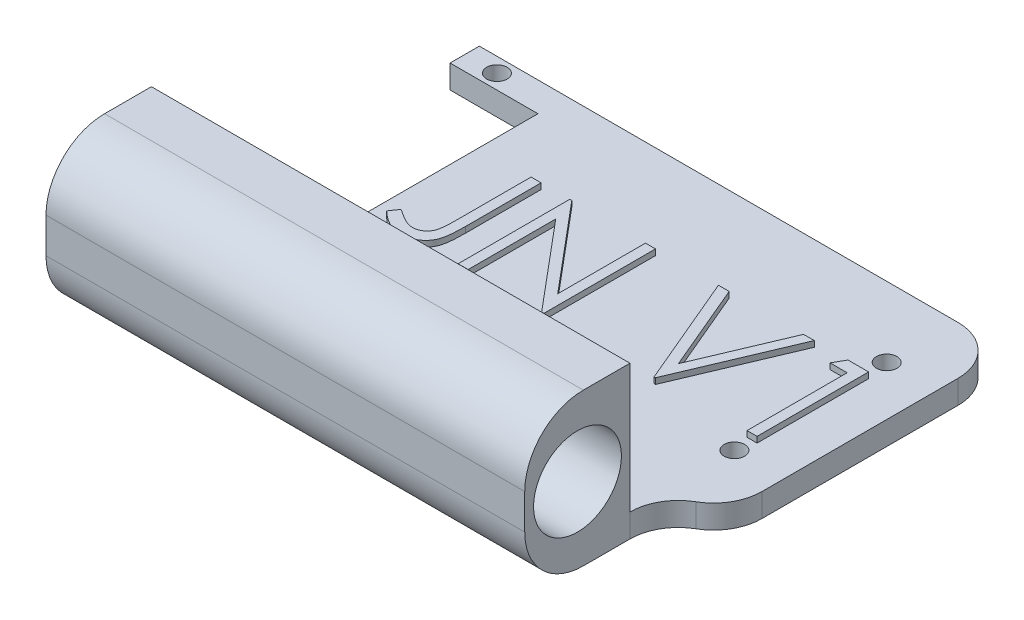
from build123d import *

# Parameters (mm, degrees)
SKETCH1_R           = 1.75
BOSS_EXTRUDE1_DEPTH = 4
FILLET1_R           = 8.25
SKETCH2_W           = 81.75
SKETCH2_H           = 4
BOSS_EXTRUDE2_DEPTH = 24
FILLET3_R           = 8.25
BOSS_EXTRUDE4_DEPTH = 1
BOSS_EXTRUDE6_DEPTH = 22
SKETCH7_R           = 7.5
CUT_EXTRUDE2_DEPTH  = 115
FILLET6_R           = 10


with BuildPart() as part:
    # Sketch1 → Boss-Extrude1 (new body)
    with BuildSketch(Plane(origin=(0, 0, 0), x_dir=(1, 0, 0), z_dir=(0, 1, 0))):
        Polygon((0, 45), (15, 45), (15, 5), (0, 5), (0, 0), (90, 0), (90, 50), (0, 50), align=None)
        with Locations(Location((5.5, 2.5, 0), (0, 0, 270))):
            Circle(SKETCH1_R, mode=Mode.SUBTRACT)
        with Locations(Location((5.5, 47.5, 0), (0, 0, 270))):
            Circle(SKETCH1_R, mode=Mode.SUBTRACT)
        with Locations(Location((81.55, 12, 0), (0, 0, 270))):
            Circle(SKETCH1_R, mode=Mode.SUBTRACT)
        with Locations(Location((81.55, 38, 0), (0, 0, 270))):
            Circle(SKETCH1_R, mode=Mode.SUBTRACT)
    extrude(amount=BOSS_EXTRUDE1_DEPTH)

    # Fillet1
    fillet1_edges = [part.edges().sort_by_distance(p)[0] for p in [
        (90, 2, -50),
        (90, 2, 0),
    ]]
    fillet(fillet1_edges, radius=FILLET1_R)

    # Sketch2 → Boss-Extrude2 (add)
    with BuildSketch(Plane.XY):
        with Locations((40.875, 2)):
            Rectangle(SKETCH2_W, SKETCH2_H)
    extrude(amount=BOSS_EXTRUDE2_DEPTH)

    # Fillet3
    fillet3_edges = [part.edges().sort_by_distance(p)[0] for p in [
        (81.75, 2, 0),
    ]]
    fillet(fillet3_edges, radius=FILLET3_R)

    # Sketch5 → Boss-Extrude4 (add)
    with BuildSketch(Plane(origin=(0, 4, 0), x_dir=(1, 0, 0), z_dir=(0, 1, 0))):
        Polygon((78.896003606, 34.05), (82.418269231, 34.05), (82.418269231, 15), (80.708653846, 15), (80.708653846, 32.096153846), (77.777884615, 32.096153846), align=None)
        Polygon((56.774038462, 34.05), (58.605769231, 34.05), (64.955769231, 19.037439904), (71.305769231, 34.05), (73.1375, 34.05), (65.077884615, 15), (64.833653846, 15), align=None)
        Polygon((31.374038462, 15), (31.374038462, 34.05), (31.732752404, 34.05), (44.318269231, 19.056520433), (44.318269231, 34.05), (46.027884615, 34.05), (46.027884615, 15), (45.638641827, 15), (33.083653846, 29.959134615), (33.083653846, 15), align=None)
        with BuildLine():
            Line((24.779807692, 34.05), (26.489423077, 34.05))
            Line((26.489423077, 34.05), (26.489423077, 21.185907452))
            add(Edge.make_bspline(
                [(26.489423077, 21.185907452), (26.487714463, 20.94802645), (26.484433715, 20.4912659), (26.466393852, 19.833366552), (26.433010208, 19.232634675), (26.384378211, 18.68770427), (26.319498087, 18.200282505), (26.245251919, 17.766603171), (26.155375115, 17.390285757), (26.020030491, 16.967727607), (25.798103714, 16.504302041), (25.464091692, 16.003803293), (25.049167471, 15.566015729), (24.568557562, 15.185817326), (24.018061417, 14.882882968), (23.409015395, 14.66541264), (22.745168684, 14.532765549), (22.284707257, 14.518756151), (22.047475962, 14.511538462)],
                knots=[0, 0, 0, 0, 1.237770943, 2.376671248, 3.424123796, 4.367912054, 5.222547132, 5.982086412, 6.656319012, 7.234008312, 8.288027371, 9.317870876, 10.352700517, 11.413286737, 12.494591526, 13.606319346, 14.766767577, 16, 16, 16, 16], degree=3))
            add(Edge.make_bspline(
                [(22.047475962, 14.511538462), (21.862645469, 14.517420063), (21.490754275, 14.529254234), (20.937266275, 14.625710986), (20.385349806, 14.774388308), (19.832075492, 14.99211672), (19.266512335, 15.28823862), (18.681000534, 15.675687408), (18.068008595, 16.153741858), (17.664239566, 16.518618731), (17.452884615, 16.709615385)],
                knots=[0, 0, 0, 0, 0.848567217, 1.707373443, 2.573483905, 3.470863513, 4.432650262, 5.500696352, 6.691726801, 8, 8, 8, 8], degree=3))
            Line((17.452884615, 16.709615385), (18.460336538, 18.175))
            add(Edge.make_bspline(
                [(18.460336538, 18.175), (18.69276112, 18.014722029), (19.131609036, 17.712096322), (19.776611779, 17.322787254), (20.348096283, 16.989003138), (20.721927753, 16.818901448), (20.895012019, 16.740144231)],
                knots=[0, 0, 0, 0, 1.196737151, 2.259595785, 3.194191475, 4, 4, 4, 4], degree=3))
            add(Edge.make_bspline(
                [(20.895012019, 16.740144231), (20.999973772, 16.698999184), (21.205827143, 16.618304586), (21.520560791, 16.528247625), (21.833498063, 16.47903108), (22.040967226, 16.469879824), (22.142878606, 16.465384615)],
                knots=[0, 0, 0, 0, 1.051806502, 2.062826769, 3.048436908, 4, 4, 4, 4], degree=3))
            add(Edge.make_bspline(
                [(22.142878606, 16.465384615), (22.274502068, 16.470951216), (22.534673123, 16.481954332), (22.912755719, 16.579105387), (23.274477289, 16.72739278), (23.606870712, 16.944515394), (23.913224033, 17.202677841), (24.166005698, 17.514858402), (24.376738129, 17.860838972), (24.503555031, 18.1883436), (24.584353004, 18.487029259), (24.635633573, 18.761529612), (24.680475425, 19.082448517), (24.719563586, 19.450169036), (24.742447919, 19.86542737), (24.768123361, 20.327004205), (24.777404852, 20.83606327), (24.778982306, 21.190997165), (24.779807692, 21.37671274)],
                knots=[0, 0, 0, 0, 0.997221856, 1.971139923, 2.944579524, 3.951425367, 4.971190333, 5.972282193, 6.985401279, 8.033996657, 8.624075553, 9.332086008, 10.151144245, 11.082816738, 12.137127781, 13.306538797, 14.590673636, 16, 16, 16, 16], degree=3))
            Line((24.779807692, 21.37671274), (24.779807692, 34.05))
        make_face()
    extrude(amount=BOSS_EXTRUDE4_DEPTH)

    # Sketch6 → Boss-Extrude6 (add)
    with BuildSketch(Plane(origin=(0, 4, 0), x_dir=(1, 0, 0), z_dir=(0, 1, 0))):
        Polygon((0, -24), (0, -6), (81.75, -6.039419162), (81.75, -24), align=None)
    extrude(amount=BOSS_EXTRUDE6_DEPTH)

    # Sketch7 → Cut-Extrude2 (cut)
    with BuildSketch(Plane.ZY):
        with Locations((15, 13)):
            Circle(SKETCH7_R)
    extrude(amount=-CUT_EXTRUDE2_DEPTH, mode=Mode.SUBTRACT)

    # Fillet6
    fillet6_edges = [part.edges().sort_by_distance(p)[0] for p in [
        (40.875, 26, 24),
        (40.875, 0, 24),
    ]]
    fillet(fillet6_edges, radius=FILLET6_R)


solid = part.part
